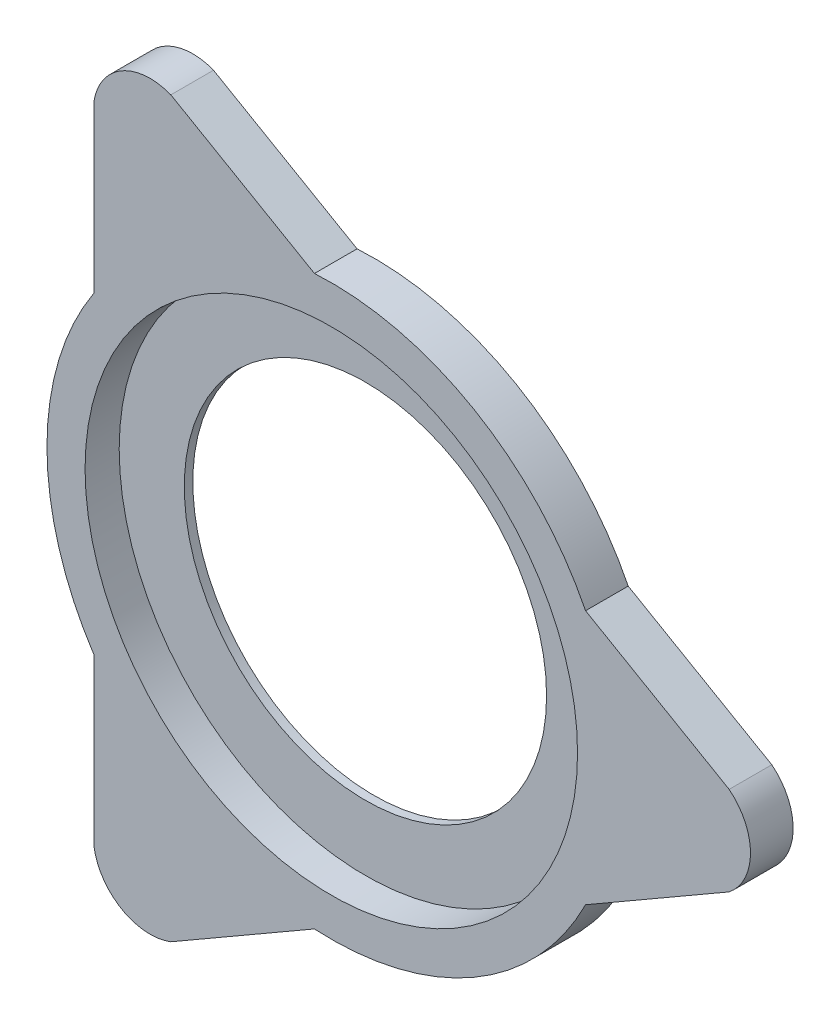
from build123d import *

# Parameters (mm, degrees)
SKETCH1_R          = 40.456394747
BASE_EXTRUDE_DEPTH = 9.525
SKETCH2_R          = 54.991944722
CUT_EXTRUDE1_DEPTH = 7.62


with BuildPart() as part:
    # Sketch1 → Base-Extrude (new body)
    with BuildSketch(Plane.XY):
        with BuildLine():
            Line((88.84522521, -9.917986872), (56.779605871, -28.43108083))
            ThreePointArc((56.779605871, -28.43108083), (31.75, -54.99261314), (-3.76776468, -63.388121516))
            Line((-3.76776468, -63.388121516), (-35.833384019, -81.901215473))
            ThreePointArc((-35.833384019, -81.901215473), (-46.806394747, -81.07105382), (-53.011841191, -71.983228601))
            Line((-53.011841191, -71.983228601), (-53.011841191, -34.957040686))
            ThreePointArc((-53.011841191, -34.957040686), (-63.5, 0), (-53.011841191, 34.957040686))
            Line((-53.011841191, 34.957040686), (-53.011841191, 71.983228601))
            ThreePointArc((-53.011841191, 71.983228601), (-46.806394747, 81.07105382), (-35.833384019, 81.901215473))
            Line((-35.833384019, 81.901215473), (-3.76776468, 63.388121516))
            ThreePointArc((-3.76776468, 63.388121516), (31.75, 54.99261314), (56.779605871, 28.43108083))
            Line((56.779605871, 28.43108083), (88.84522521, 9.917986872))
            ThreePointArc((88.84522521, 9.917986872), (93.612789493, 0), (88.84522521, -9.917986872))
        make_face()
        Circle(SKETCH1_R, mode=Mode.SUBTRACT)
    extrude(amount=BASE_EXTRUDE_DEPTH)

    # Sketch2 → Cut-Extrude1 (cut)
    with BuildSketch(Plane.XY.offset(9.525)):
        Circle(SKETCH2_R)
    extrude(amount=-CUT_EXTRUDE1_DEPTH, mode=Mode.SUBTRACT)


solid = part.part
